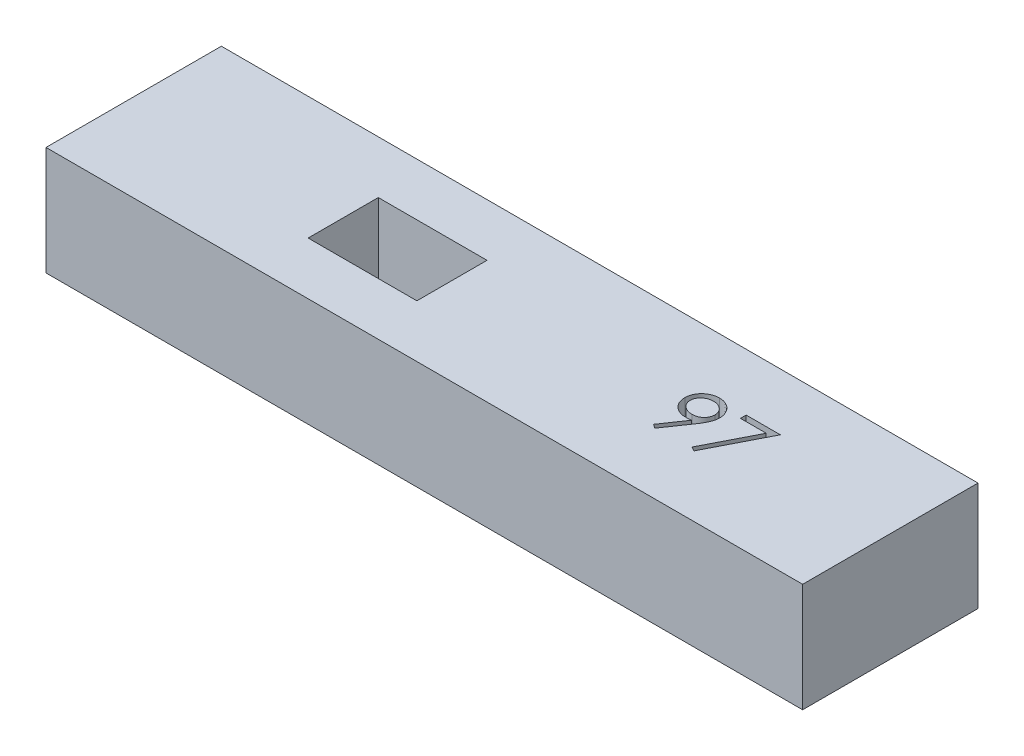
from build123d import *

# Parameters (mm, degrees)
SKETCH2_W           = 6.2
SKETCH2_H           = 4
BOSS_EXTRUDE1_DEPTH = 6.2
CUT_EXTRUDE1_DEPTH  = 1


with BuildPart() as part:
    # Sketch2 → Boss-Extrude1 (new body)
    with BuildSketch(Plane(origin=(0, 0, 0), x_dir=(1, 0, 0), z_dir=(0, 1, 0))):
        Polygon((-0.1, 7), (6.2, 7), (31.2, 7), (31.2, -3), (6.2, -3), (-0.1, -3), (-11.95, -3), (-11.95, 7), align=None)
        with Locations((3.1, 2)):
            Rectangle(SKETCH2_W, SKETCH2_H, mode=Mode.SUBTRACT)
    extrude(amount=BOSS_EXTRUDE1_DEPTH)

    # Sketch3 → Cut-Extrude1 (cut)
    with BuildSketch(Plane(origin=(0, 6.2, 0), x_dir=(1, 0, 0), z_dir=(0, 1, 0))):
        with BuildLine():
            Line((19.276089489, 0.490389836), (19.048395179, 0.648758226))
            Line((19.048395179, 0.648758226), (19.931187647, 1.939237994))
            add(Edge.make_bspline(
                [(19.931187647, 1.939237994), (19.874862479, 1.93235), (19.763955085, 1.918787158), (19.652252142, 1.91629555), (19.597278392, 1.915069324)],
                knots=[0, 0, 0, 0, 0.000170115, 0.000334967, 0.000334967, 0.000334967, 0.000334967], degree=3))
            add(Edge.make_bspline(
                [(19.597278392, 1.915069324), (19.563948105, 1.915923014), (19.498523668, 1.917598735), (19.402337812, 1.930880947), (19.309913054, 1.951337134), (19.221494424, 1.981861362), (19.136749587, 2.019796451), (19.055863547, 2.066838171), (18.978945189, 2.122179593), (18.90682061, 2.185528092), (18.841223533, 2.25508604), (18.782782398, 2.328705801), (18.734212943, 2.407242575), (18.693866326, 2.489094274), (18.663267986, 2.575437356), (18.640986256, 2.665289312), (18.62726812, 2.759279873), (18.625636083, 2.823256242), (18.624807438, 2.855739396)],
                knots=[0, 0, 0, 0, 9.9954e-05, 0.000196201, 0.000290782, 0.000383503, 0.000476303, 0.000568919, 0.000663705, 0.000760153, 0.000856434, 0.000950205, 0.001041624, 0.001132931, 0.001223461, 0.001315861, 0.001410305, 0.001507717, 0.001507717, 0.001507717, 0.001507717], degree=3))
            add(Edge.make_bspline(
                [(18.624807438, 2.855739396), (18.626380818, 2.900160959), (18.629469044, 2.987351477), (18.654323414, 3.114744968), (18.695199578, 3.235201332), (18.752193892, 3.348403865), (18.823980389, 3.45272415), (18.910257467, 3.54671196), (19.010500349, 3.629030506), (19.122425466, 3.699791348), (19.243395707, 3.756700952), (19.370095132, 3.798646603), (19.501552941, 3.823319753), (19.590605042, 3.826572641), (19.635439449, 3.828210349)],
                knots=[0, 0, 0, 0, 0.000133185, 0.000261414, 0.000387724, 0.00051373, 0.000640399, 0.00076644, 0.000895188, 0.001028407, 0.001162697, 0.001295241, 0.001427846, 0.0015623, 0.0015623, 0.0015623, 0.0015623], degree=3))
            add(Edge.make_bspline(
                [(19.635439449, 3.828210349), (19.679425373, 3.82655013), (19.766337412, 3.823269693), (19.894143868, 3.79924495), (20.016554647, 3.758753111), (20.132891171, 3.702796399), (20.240604781, 3.63265529), (20.337465695, 3.549076115), (20.421263506, 3.452006815), (20.491860883, 3.343795114), (20.548530134, 3.227529352), (20.589417134, 3.106168222), (20.614586392, 2.980584525), (20.61775806, 2.895499538), (20.61935872, 2.852559308)],
                knots=[0, 0, 0, 0, 0.000131915, 0.000260652, 0.000388569, 0.000517718, 0.000646848, 0.000773094, 0.000900237, 0.001030248, 0.001159674, 0.001287189, 0.001413545, 0.001542287, 0.001542287, 0.001542287, 0.001542287], degree=3))
            add(Edge.make_bspline(
                [(20.61935872, 2.852559308), (20.618289735, 2.819227462), (20.616121566, 2.75162215), (20.600939344, 2.648906053), (20.575158176, 2.544175295), (20.545901278, 2.455527847), (20.517659955, 2.382313754), (20.491079642, 2.324481963), (20.461586475, 2.263611531), (20.427188737, 2.200340732), (20.390211511, 2.133863004), (20.348429167, 2.064845112), (20.302794827, 1.993194439), (20.270292153, 1.944891724), (20.253648584, 1.920157465)],
                knots=[0, 0, 0, 0, 9.9984e-05, 0.000202793, 0.000310776, 0.000423207, 0.000482616, 0.000546097, 0.000614079, 0.0006855, 0.000762103, 0.000842274, 0.000927493, 0.001016928, 0.001016928, 0.001016928, 0.001016928], degree=3))
            Line((20.253648584, 1.920157465), (19.276089489, 0.490389836))
        make_face()
        with BuildLine():
            add(Edge.make_bspline(
                [(19.650067855, 2.240710349), (19.675317282, 2.241400126), (19.724469333, 2.242742887), (19.796475883, 2.250915556), (19.864442839, 2.265406244), (19.928551758, 2.286197697), (19.989445447, 2.311286246), (20.046156688, 2.343228548), (20.098732942, 2.381343638), (20.147526275, 2.424169867), (20.190855047, 2.471750039), (20.229447653, 2.521549557), (20.262250454, 2.573787025), (20.288161426, 2.629116627), (20.309465291, 2.686191523), (20.324177345, 2.745930831), (20.332327419, 2.808023309), (20.333716776, 2.850204234), (20.334422823, 2.871639836)],
                knots=[0, 0, 0, 0, 7.5753e-05, 0.000147465, 0.000217073, 0.000283852, 0.000349411, 0.000414338, 0.000478589, 0.000543925, 0.000608743, 0.000671332, 0.000732749, 0.000793345, 0.000854313, 0.000915245, 0.00097749, 0.001041807, 0.001041807, 0.001041807, 0.001041807], degree=3))
            add(Edge.make_bspline(
                [(20.334422823, 2.871639836), (20.333815337, 2.89308439), (20.332618212, 2.935343513), (20.323014019, 2.99752792), (20.306118281, 3.057121092), (20.283448341, 3.114449282), (20.253584983, 3.169041477), (20.217749678, 3.221583075), (20.175175241, 3.271740933), (20.126187199, 3.318335404), (20.07336014, 3.361286713), (20.017062401, 3.399192653), (19.957758012, 3.430961881), (19.895808782, 3.457177375), (19.831085637, 3.477635058), (19.763626877, 3.492346524), (19.693091616, 3.500485187), (19.645211449, 3.501865763), (19.620811044, 3.502569324)],
                knots=[0, 0, 0, 0, 6.4316e-05, 0.000126743, 0.000188161, 0.000249812, 0.000311283, 0.000374438, 0.00044032, 0.000508243, 0.00057698, 0.000644365, 0.000711521, 0.0007785, 0.000845884, 0.000914871, 0.00098532, 0.001058531, 0.001058531, 0.001058531, 0.001058531], degree=3))
            add(Edge.make_bspline(
                [(19.620811044, 3.502569324), (19.596622848, 3.501864626), (19.549165806, 3.500482016), (19.479257604, 3.492361994), (19.412254973, 3.477536119), (19.347719361, 3.457186851), (19.285771971, 3.430959926), (19.22647038, 3.399190988), (19.170159472, 3.361295438), (19.117383061, 3.318301609), (19.068308518, 3.271957816), (19.026466073, 3.221363348), (18.990548757, 3.169068808), (18.960726433, 3.114442018), (18.938045578, 3.057123031), (18.921152762, 2.997527395), (18.911547784, 2.93534365), (18.910350767, 2.893084436), (18.909743336, 2.871639836)],
                knots=[0, 0, 0, 0, 7.2576e-05, 0.000142393, 0.000210758, 0.000278143, 0.000345121, 0.000412278, 0.000479663, 0.0005484, 0.000616323, 0.000681795, 0.00074495, 0.000806421, 0.000868072, 0.00092949, 0.000991917, 0.001056233, 0.001056233, 0.001056233, 0.001056233], degree=3))
            add(Edge.make_bspline(
                [(18.909743336, 2.871639836), (18.910292997, 2.850187542), (18.91137703, 2.807879691), (18.921834382, 2.745716463), (18.939322536, 2.686127887), (18.962744412, 2.62853456), (18.993588712, 2.573496517), (19.031438202, 2.521274696), (19.075802519, 2.471277109), (19.126088611, 2.424280567), (19.1811233, 2.38114395), (19.239903206, 2.343469961), (19.301416415, 2.311654244), (19.365879466, 2.286125988), (19.432814634, 2.265613979), (19.502823503, 2.250942263), (19.575674547, 2.242821278), (19.625032174, 2.241420743), (19.650067855, 2.240710349)],
                knots=[0, 0, 0, 0, 6.4316e-05, 0.000126844, 0.000188436, 0.000250326, 0.000312966, 0.000377217, 0.000443451, 0.000513196, 0.000583426, 0.000652939, 0.000722346, 0.000790847, 0.000860662, 0.000932137, 0.001005113, 0.00108023, 0.00108023, 0.00108023, 0.00108023], degree=3))
        make_face(mode=Mode.SUBTRACT)
        Polygon((21.229935643, 3.746800093), (23.183781797, 3.746800093), (21.514871541, 0.490389836), (21.268732719, 0.625861591), (22.701680435, 3.421159067), (21.229935643, 3.421159067), align=None)
    extrude(amount=-CUT_EXTRUDE1_DEPTH, mode=Mode.SUBTRACT)


solid = part.part
